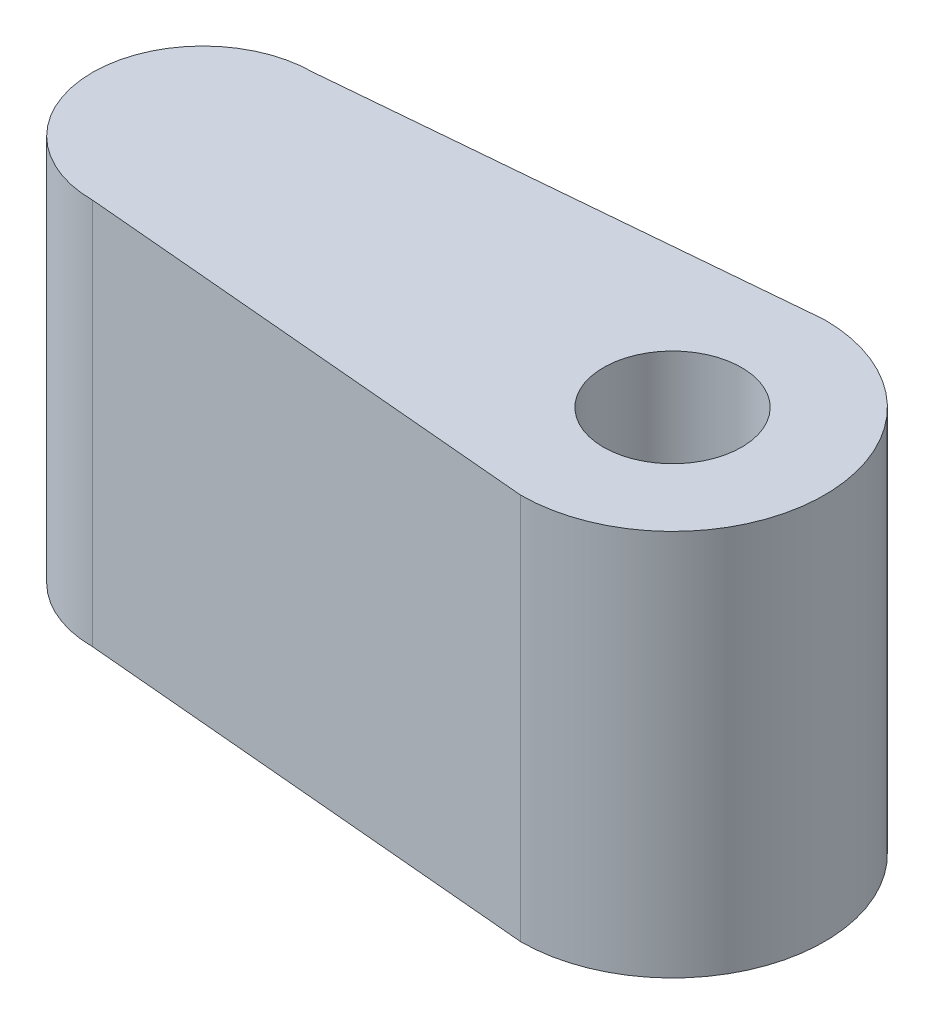
from build123d import *

# Parameters (mm, degrees)
SKETCH1_R           = 1.25
BOSS_EXTRUDE1_DEPTH = 7
SKETCH2_R           = 1.2
CUT_EXTRUDE1_DEPTH  = 8


with BuildPart() as part:
    # Sketch1 → Boss-Extrude1 (new body)
    with BuildSketch(Plane(origin=(0, 0, 0), x_dir=(1, 0, 0), z_dir=(0, 1, 0))):
        with BuildLine():
            Line((-0.481545064, 2.70751073), (-8.5, 2))
            ThreePointArc((-8.5, 2), (-10.5, 0), (-8.5, -2))
            Line((-8.5, -2), (-0.481545064, -2.70751073))
            Line((-0.481545064, -2.70751073), (0, -2.75))
            ThreePointArc((0, -2.75), (2.75, 0), (0, 2.75))
            Line((0, 2.75), (-0.481545064, 2.70751073))
        make_face()
        Circle(SKETCH1_R, mode=Mode.SUBTRACT)
    extrude(amount=BOSS_EXTRUDE1_DEPTH)

    # Sketch2 → Cut-Extrude1 (cut)
    with BuildSketch(Plane.ZY.offset(10.5)):
        with Locations((0, 3.5)):
            Circle(SKETCH2_R)
    extrude(amount=-CUT_EXTRUDE1_DEPTH, mode=Mode.SUBTRACT)


solid = part.part
